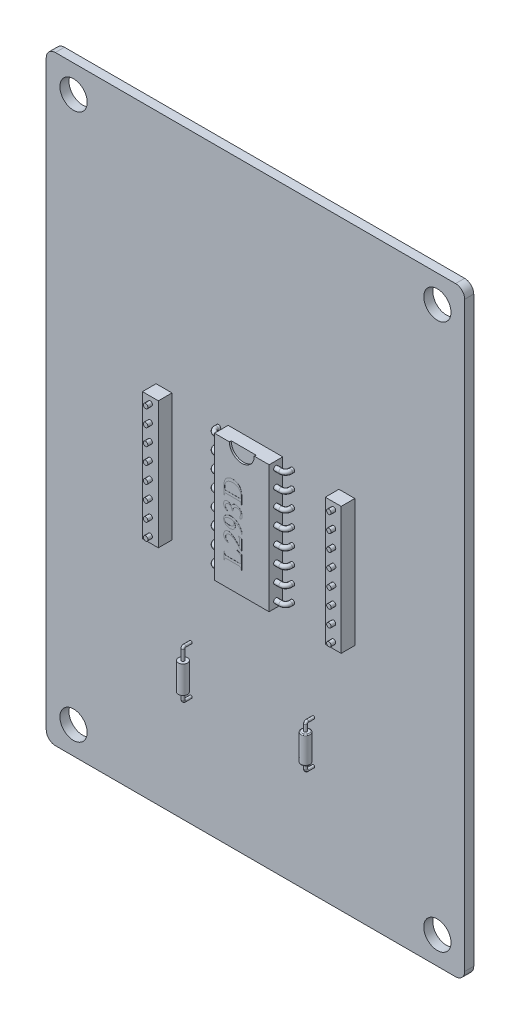
from build123d import *

# Parameters (mm, degrees)
ESQUISSE1_W                = 46
ESQUISSE1_H                = 66
ESQUISSE1_R                = 1.5
BOSS_EXTRU_1_DEPTH         = 1
CONG_1_R                   = 1
ESQUISSE2_W                = 6
ESQUISSE2_H                = 14
BOSS_EXTRU_2_DEPTH         = 1.5
ESQUISSE3_R                = 0.25
R_P_TITION_LIN_AIRE1_COUNT = 4
R_P_TITION_LIN_AIRE1_PITCH = 1.8
SYM_TRIE1_COPY_1_SKETCH_R  = 0.25
SYM_TRIE1_COPY_2_SKETCH_R  = 0.25
SYM_TRIE1_COPY_3_SKETCH_R  = 0.25
SYM_TRIE2_COPY_1_SKETCH_R  = 0.25
SYM_TRIE2_COPY_2_SKETCH_R  = 0.25
SYM_TRIE2_COPY_3_SKETCH_R  = 0.25
SYM_TRIE2_COPY_4_SKETCH_R  = 0.25
SYM_TRIE2_COPY_5_SKETCH_R  = 0.25
SYM_TRIE2_COPY_6_SKETCH_R  = 0.25
SYM_TRIE2_COPY_7_SKETCH_R  = 0.25
ENL_V_MAT_EXTRU_1_DEPTH    = 0.2
ESQUISSE7_W                = 1.747705219
ESQUISSE7_H                = 14
BOSS_EXTRU_6_DEPTH         = 1.5
BOSS_EXTRU_6_2_DEPTH       = 1.5
ESQUISSE8_R                = 0.25
BOSS_EXTRU_7_DEPTH         = 2
BOSS_EXTRU_8_START         = -20
ESQUISSE9_R                = 0.5
BOSS_EXTRU_8_DEPTH         = 3
BOSS_EXTRU_8_2_DEPTH       = 3
BOSS_EXTRU_9_START         = 0.5
ESQUISSE10_R               = 0.15
BOSS_EXTRU_9_DEPTH         = 4
ESQUISSE11_R               = 0.15
ESQUISSE12_R               = 0.15
CONG_2_R                   = 0.1
ESQUISSE13_R               = 0.15
ESQUISSE14_R               = 0.15
BOSS_EXTRU_10_DEPTH        = 0.01


with BuildPart() as part:
    # Esquisse1 → Boss.-Extru.1 (new body)
    with BuildSketch(Plane.XY):
        Rectangle(ESQUISSE1_W, ESQUISSE1_H)
        with Locations((-20, 30)):
            Circle(ESQUISSE1_R, mode=Mode.SUBTRACT)
        with Locations((20, 30)):
            Circle(ESQUISSE1_R, mode=Mode.SUBTRACT)
        with Locations((20, -30)):
            Circle(ESQUISSE1_R, mode=Mode.SUBTRACT)
        with Locations((-20, -30)):
            Circle(ESQUISSE1_R, mode=Mode.SUBTRACT)
    extrude(amount=BOSS_EXTRU_1_DEPTH)

    # Congé1
    cong_1_edges = [part.edges().sort_by_distance(p)[0] for p in [
        (23, 33, 0.5),
        (23, -33, 0.5),
        (-23, -33, 0.5),
        (-23, 33, 0.5),
    ]]
    fillet(cong_1_edges, radius=CONG_1_R)

    # Esquisse2 → Boss.-Extru.2 (add)
    with BuildSketch(Plane.XY.offset(1)):
        Rectangle(ESQUISSE2_W, ESQUISSE2_H)
    extrude(amount=BOSS_EXTRU_2_DEPTH)

    # Balayage1: sweep along a curve in space
    with BuildLine() as balayage1_path:
        Line((3, 0.9, 1.75), (3.563213592, 0.9, 1.75))
        ThreePointArc((3.563213592, 0.9, 1.75), (3.916766983, 0.9, 1.603553391), (4.063213592, 0.9, 1.25))
        Line((4.063213592, 0.9, 1.25), (4.063213592, 0.9, 0.607286013))
    # Esquisse3 → Balayage1 (sweep)
    with BuildSketch(Plane(origin=(3, 0, 0), x_dir=(0, 0, -1), z_dir=(1, 0, 0))):
        with Locations((-1.75, 0.9)):
            Circle(ESQUISSE3_R)
    balayage1 = sweep(path=balayage1_path.line)

    # Répétition linéaire1: Balayage1 ×4
    with Locations(*[(0, i * R_P_TITION_LIN_AIRE1_PITCH, 0) for i in range(1, R_P_TITION_LIN_AIRE1_COUNT)]):
        add(balayage1)

    # Symétrie1: Balayage1 across plane
    add(balayage1.mirror(Plane.ZX))

    # Symétrie1 copy 1: sweep along a curve in space
    with BuildLine() as sym_trie1_copy_1_path:
        Line((3, -2.7, 1.75), (3.563213592, -2.7, 1.75))
        ThreePointArc((3.563213592, -2.7, 1.75), (3.916766983, -2.7, 1.603553391), (4.063213592, -2.7, 1.25))
        Line((4.063213592, -2.7, 1.25), (4.063213592, -2.7, 0.607286013))
    # Symétrie1 copy 1 sketch → Symétrie1 copy 1 (sweep)
    with BuildSketch(Plane(origin=(3, -1.8, 0), x_dir=(0, 0, -1), z_dir=(1, 0, 0))):
        with Locations((-1.75, -0.9)):
            Circle(SYM_TRIE1_COPY_1_SKETCH_R)
    sweep(path=sym_trie1_copy_1_path.line)

    # Symétrie1 copy 2: sweep along a curve in space
    with BuildLine() as sym_trie1_copy_2_path:
        Line((3, -4.5, 1.75), (3.563213592, -4.5, 1.75))
        ThreePointArc((3.563213592, -4.5, 1.75), (3.916766983, -4.5, 1.603553391), (4.063213592, -4.5, 1.25))
        Line((4.063213592, -4.5, 1.25), (4.063213592, -4.5, 0.607286013))
    # Symétrie1 copy 2 sketch → Symétrie1 copy 2 (sweep)
    with BuildSketch(Plane(origin=(3, -3.6, 0), x_dir=(0, 0, -1), z_dir=(1, 0, 0))):
        with Locations((-1.75, -0.9)):
            Circle(SYM_TRIE1_COPY_2_SKETCH_R)
    sweep(path=sym_trie1_copy_2_path.line)

    # Symétrie1 copy 3: sweep along a curve in space
    with BuildLine() as sym_trie1_copy_3_path:
        Line((3, -6.3, 1.75), (3.563213592, -6.3, 1.75))
        ThreePointArc((3.563213592, -6.3, 1.75), (3.916766983, -6.3, 1.603553391), (4.063213592, -6.3, 1.25))
        Line((4.063213592, -6.3, 1.25), (4.063213592, -6.3, 0.607286013))
    # Symétrie1 copy 3 sketch → Symétrie1 copy 3 (sweep)
    with BuildSketch(Plane(origin=(3, -5.4, 0), x_dir=(0, 0, -1), z_dir=(1, 0, 0))):
        with Locations((-1.75, -0.9)):
            Circle(SYM_TRIE1_COPY_3_SKETCH_R)
    sweep(path=sym_trie1_copy_3_path.line)

    # Symétrie2: Balayage1 across plane
    add(balayage1.mirror(Plane(origin=(0, 0, 0), x_dir=(0, 0, 1), z_dir=(1, 0, 0))))

    # Symétrie2 copy 1: sweep along a curve in space
    with BuildLine() as sym_trie2_copy_1_path:
        Line((-3, 2.7, 1.75), (-3.563213592, 2.7, 1.75))
        ThreePointArc((-3.563213592, 2.7, 1.75), (-3.916766983, 2.7, 1.603553391), (-4.063213592, 2.7, 1.25))
        Line((-4.063213592, 2.7, 1.25), (-4.063213592, 2.7, 0.607286013))
    # Symétrie2 copy 1 sketch → Symétrie2 copy 1 (sweep)
    with BuildSketch(Plane(origin=(-3, 1.8, 0), x_dir=(0, 0, -1), z_dir=(-1, 0, 0))):
        with Locations((-1.75, -0.9)):
            Circle(SYM_TRIE2_COPY_1_SKETCH_R)
    sweep(path=sym_trie2_copy_1_path.line)

    # Symétrie2 copy 2: sweep along a curve in space
    with BuildLine() as sym_trie2_copy_2_path:
        Line((-3, 4.5, 1.75), (-3.563213592, 4.5, 1.75))
        ThreePointArc((-3.563213592, 4.5, 1.75), (-3.916766983, 4.5, 1.603553391), (-4.063213592, 4.5, 1.25))
        Line((-4.063213592, 4.5, 1.25), (-4.063213592, 4.5, 0.607286013))
    # Symétrie2 copy 2 sketch → Symétrie2 copy 2 (sweep)
    with BuildSketch(Plane(origin=(-3, 3.6, 0), x_dir=(0, 0, -1), z_dir=(-1, 0, 0))):
        with Locations((-1.75, -0.9)):
            Circle(SYM_TRIE2_COPY_2_SKETCH_R)
    sweep(path=sym_trie2_copy_2_path.line)

    # Symétrie2 copy 3: sweep along a curve in space
    with BuildLine() as sym_trie2_copy_3_path:
        Line((-3, 6.3, 1.75), (-3.563213592, 6.3, 1.75))
        ThreePointArc((-3.563213592, 6.3, 1.75), (-3.916766983, 6.3, 1.603553391), (-4.063213592, 6.3, 1.25))
        Line((-4.063213592, 6.3, 1.25), (-4.063213592, 6.3, 0.607286013))
    # Symétrie2 copy 3 sketch → Symétrie2 copy 3 (sweep)
    with BuildSketch(Plane(origin=(-3, 5.4, 0), x_dir=(0, 0, -1), z_dir=(-1, 0, 0))):
        with Locations((-1.75, -0.9)):
            Circle(SYM_TRIE2_COPY_3_SKETCH_R)
    sweep(path=sym_trie2_copy_3_path.line)

    # Symétrie2 copy 4: sweep along a curve in space
    with BuildLine() as sym_trie2_copy_4_path:
        Line((-3, -0.9, 1.75), (-3.563213592, -0.9, 1.75))
        ThreePointArc((-3.563213592, -0.9, 1.75), (-3.916766983, -0.9, 1.603553391), (-4.063213592, -0.9, 1.25))
        Line((-4.063213592, -0.9, 1.25), (-4.063213592, -0.9, 0.607286013))
    # Symétrie2 copy 4 sketch → Symétrie2 copy 4 (sweep)
    with BuildSketch(Plane(origin=(-3, 0, 0), x_dir=(0, 0, -1), z_dir=(-1, 0, 0))):
        with Locations((-1.75, 0.9)):
            Circle(SYM_TRIE2_COPY_4_SKETCH_R)
    sweep(path=sym_trie2_copy_4_path.line)

    # Symétrie2 copy 5: sweep along a curve in space
    with BuildLine() as sym_trie2_copy_5_path:
        Line((-3, -2.7, 1.75), (-3.563213592, -2.7, 1.75))
        ThreePointArc((-3.563213592, -2.7, 1.75), (-3.916766983, -2.7, 1.603553391), (-4.063213592, -2.7, 1.25))
        Line((-4.063213592, -2.7, 1.25), (-4.063213592, -2.7, 0.607286013))
    # Symétrie2 copy 5 sketch → Symétrie2 copy 5 (sweep)
    with BuildSketch(Plane(origin=(-3, -1.8, 0), x_dir=(0, 0, -1), z_dir=(-1, 0, 0))):
        with Locations((-1.75, 0.9)):
            Circle(SYM_TRIE2_COPY_5_SKETCH_R)
    sweep(path=sym_trie2_copy_5_path.line)

    # Symétrie2 copy 6: sweep along a curve in space
    with BuildLine() as sym_trie2_copy_6_path:
        Line((-3, -4.5, 1.75), (-3.563213592, -4.5, 1.75))
        ThreePointArc((-3.563213592, -4.5, 1.75), (-3.916766983, -4.5, 1.603553391), (-4.063213592, -4.5, 1.25))
        Line((-4.063213592, -4.5, 1.25), (-4.063213592, -4.5, 0.607286013))
    # Symétrie2 copy 6 sketch → Symétrie2 copy 6 (sweep)
    with BuildSketch(Plane(origin=(-3, -3.6, 0), x_dir=(0, 0, -1), z_dir=(-1, 0, 0))):
        with Locations((-1.75, 0.9)):
            Circle(SYM_TRIE2_COPY_6_SKETCH_R)
    sweep(path=sym_trie2_copy_6_path.line)

    # Symétrie2 copy 7: sweep along a curve in space
    with BuildLine() as sym_trie2_copy_7_path:
        Line((-3, -6.3, 1.75), (-3.563213592, -6.3, 1.75))
        ThreePointArc((-3.563213592, -6.3, 1.75), (-3.916766983, -6.3, 1.603553391), (-4.063213592, -6.3, 1.25))
        Line((-4.063213592, -6.3, 1.25), (-4.063213592, -6.3, 0.607286013))
    # Symétrie2 copy 7 sketch → Symétrie2 copy 7 (sweep)
    with BuildSketch(Plane(origin=(-3, -5.4, 0), x_dir=(0, 0, -1), z_dir=(-1, 0, 0))):
        with Locations((-1.75, 0.9)):
            Circle(SYM_TRIE2_COPY_7_SKETCH_R)
    sweep(path=sym_trie2_copy_7_path.line)

    # Esquisse4 → Enlèv. mat.-Extru.1 (cut)
    with BuildSketch(Plane.XY.offset(2.5)):
        with BuildLine():
            Line((-1.366788439, 7), (1.366788439, 7))
            ThreePointArc((1.366788439, 7), (0, 5.633211561), (-1.366788439, 7))
        make_face()
    extrude(amount=-ENL_V_MAT_EXTRU_1_DEPTH, mode=Mode.SUBTRACT)



with BuildPart() as body_2:
    # Esquisse7 → Boss.-Extru.6 (new body)
    with BuildSketch(Plane.XY.offset(2.5)):
        with Locations((-10.04930501, 0)):
            Rectangle(ESQUISSE7_W, ESQUISSE7_H)
    extrude(amount=-BOSS_EXTRU_6_DEPTH)

    # Esquisse8 → Boss.-Extru.7 (add)
    with BuildSketch(Plane(origin=(0, 0, 1), x_dir=(-1, 0, 0), z_dir=(0, 0, -1))):
        with Locations((-10.084279429, 0.9)):
            Circle(ESQUISSE8_R)
        with Locations((-10.080629218, 2.699996299)):
            Circle(ESQUISSE8_R)
        with Locations((-10.076979007, 4.499992598)):
            Circle(ESQUISSE8_R)
        with Locations((-10.073328797, 6.299988897)):
            Circle(ESQUISSE8_R)
        with Locations(Location((-10.073328797, -6.299988897, 0), (0, 0, 180))):
            Circle(ESQUISSE8_R)
        with Locations(Location((-10.076979007, -4.499992598, 0), (0, 0, 180))):
            Circle(ESQUISSE8_R)
        with Locations(Location((-10.080629218, -2.699996299, 0), (0, 0, 180))):
            Circle(ESQUISSE8_R)
        with Locations(Location((-10.084279429, -0.9, 0), (0, 0, 180))):
            Circle(ESQUISSE8_R)
        with Locations((10.084279429, -0.9)):
            Circle(ESQUISSE8_R)
        with Locations((10.080629218, -2.699996299)):
            Circle(ESQUISSE8_R)
        with Locations((10.076979007, -4.499992598)):
            Circle(ESQUISSE8_R)
        with Locations((10.073328797, -6.299988897)):
            Circle(ESQUISSE8_R)
        with Locations((10.073328797, 6.299988897)):
            Circle(ESQUISSE8_R)
        with Locations((10.076979007, 4.499992598)):
            Circle(ESQUISSE8_R)
        with Locations((10.080629218, 2.699996299)):
            Circle(ESQUISSE8_R)
        with Locations((10.084279429, 0.9)):
            Circle(ESQUISSE8_R)
    extrude(amount=-BOSS_EXTRU_7_DEPTH)


with BuildPart() as body_3:
    # Esquisse7 → Boss.-Extru.6 2 (new body)
    with BuildSketch(Plane.XY.offset(2.5)):
        with Locations((10.04930501, 0)):
            Rectangle(ESQUISSE7_W, ESQUISSE7_H)
    extrude(amount=-BOSS_EXTRU_6_2_DEPTH)


with BuildPart() as boss_extru_7_piece_1:
    # of the separate pieces the step leaves, piece 1, a body of its own (boss_extru_7_pieces)
    add(body_2.part.solids().sort_by_distance((-9.1754524, 7, 2.5))[0])


with BuildPart() as boss_extru_7_piece_2:
    # of the separate pieces the step leaves, piece 2, a body of its own (boss_extru_7_pieces)
    add(body_2.part.solids().sort_by_distance((10.326979007, -4.499992598, 1))[0])


with BuildPart() as boss_extru_7_piece_3:
    # of the separate pieces the step leaves, piece 3, a body of its own (boss_extru_7_pieces)
    add(body_2.part.solids().sort_by_distance((10.330629218, -2.699996299, 1))[0])


with BuildPart() as boss_extru_7_piece_4:
    # of the separate pieces the step leaves, piece 4, a body of its own (boss_extru_7_pieces)
    add(body_2.part.solids().sort_by_distance((10.334279429, -0.9, 1))[0])


with BuildPart() as boss_extru_7_piece_5:
    # of the separate pieces the step leaves, piece 5, a body of its own (boss_extru_7_pieces)
    add(body_2.part.solids().sort_by_distance((9.834279429, 0.9, 1))[0])


with BuildPart() as boss_extru_7_piece_6:
    # of the separate pieces the step leaves, piece 6, a body of its own (boss_extru_7_pieces)
    add(body_2.part.solids().sort_by_distance((9.830629218, 2.699996299, 1))[0])


with BuildPart() as boss_extru_7_piece_7:
    # of the separate pieces the step leaves, piece 7, a body of its own (boss_extru_7_pieces)
    add(body_2.part.solids().sort_by_distance((9.826979007, 4.499992598, 1))[0])


with BuildPart() as boss_extru_7_piece_8:
    # of the separate pieces the step leaves, piece 8, a body of its own (boss_extru_7_pieces)
    add(body_2.part.solids().sort_by_distance((9.823328797, 6.299988897, 1))[0])


with BuildPart() as boss_extru_7_piece_9:
    # of the separate pieces the step leaves, piece 9, a body of its own (boss_extru_7_pieces)
    add(body_2.part.solids().sort_by_distance((10.323328797, -6.299988897, 1))[0])


with BuildPart() as body_12:
    # Esquisse9 → Boss.-Extru.8 (new body)
    with BuildSketch(Plane(origin=(0, 0, 0), x_dir=(1, 0, 0), z_dir=(0, 1, 0)).offset(BOSS_EXTRU_8_START)):
        with Locations(Location((6.366458471, -1.857679009, 0), (0, 0, 270))):
            Circle(ESQUISSE9_R)
    extrude(amount=BOSS_EXTRU_8_DEPTH)

    # Esquisse10 → Boss.-Extru.9 (add)
    with BuildSketch(Plane.XZ.offset(20).offset(BOSS_EXTRU_9_START)):
        with Locations(Location((6.366458471, 1.857679009, 0), (0, 0, 270))):
            Circle(ESQUISSE10_R)
    extrude(amount=-BOSS_EXTRU_9_DEPTH)


with BuildPart() as body_13:
    # Esquisse9 → Boss.-Extru.8 2 (new body)
    with BuildSketch(Plane(origin=(0, 0, 0), x_dir=(1, 0, 0), z_dir=(0, 1, 0)).offset(BOSS_EXTRU_8_START)):
        with Locations(Location((-7.110417285, -1.857679009, 0), (0, 0, 270))):
            Circle(ESQUISSE9_R)
    extrude(amount=BOSS_EXTRU_8_2_DEPTH)


with BuildPart() as part_1:
    add(part.part)

    add(body_12.part)  # Balayage2 merges body 12
    # Balayage2: sweep along a curve in space
    with BuildLine() as balayage2_path:
        Line((6.366458471, -20.5, 1.857679009), (6.366458471, -20.593357663, 1.857679009))
        ThreePointArc((6.366458471, -20.593357663, 1.857679009), (6.366458471, -20.713565816, 1.807887162), (6.366458471, -20.763357663, 1.687679009))
        Line((6.366458471, -20.763357663, 1.687679009), (6.366458471, -20.763357663, 0.482310177))
    # Esquisse11 → Balayage2 (sweep)
    with BuildSketch(Plane.XZ.offset(20.5)):
        with Locations((6.366458471, 1.857679009)):
            Circle(ESQUISSE11_R)
    sweep(path=balayage2_path.line)

    # Balayage3: sweep along a curve in space
    with BuildLine() as balayage3_path:
        Line((6.366458471, -16.5, 1.857679009), (6.366458471, -16.288204336, 1.857679009))
        ThreePointArc((6.366458471, -16.288204336, 1.857679009), (6.366458471, -16.167996183, 1.807887162), (6.366458471, -16.118204336, 1.687679009))
        Line((6.366458471, -16.118204336, 1.687679009), (6.366458471, -16.118204336, 0.83860797))
    # Esquisse12 → Balayage3 (sweep)
    with BuildSketch(Plane(origin=(0, -16.5, 0), x_dir=(1, 0, 0), z_dir=(0, 1, 0))):
        with Locations((6.366458471, -1.857679009)):
            Circle(ESQUISSE12_R)
    sweep(path=balayage3_path.line)

    # Congé2
    cong_2_edges = [part_1.edges().sort_by_distance(p)[0] for p in [
        (6.366458471, -20, 1.357679009),
        (6.366458471, -17, 1.357679009),
    ]]
    fillet(cong_2_edges, radius=CONG_2_R)


    add(body_13.part)  # Balayage4 merges body 13
    # Balayage4: sweep along a curve in space
    with BuildLine() as balayage4_path:
        Line((-7.110417285, -20, 1.857679009), (-7.110417285, -20.721237624, 1.857679009))
        ThreePointArc((-7.110417285, -20.721237624, 1.857679009), (-7.110417285, -20.841445777, 1.807887162), (-7.110417285, -20.891237624, 1.687679009))
        Line((-7.110417285, -20.891237624, 1.687679009), (-7.110417285, -20.891237624, 0.537103228))
    # Esquisse13 → Balayage4 (sweep)
    with BuildSketch(Plane.XZ.offset(20)):
        with Locations((-7.110417285, 1.857679009)):
            Circle(ESQUISSE13_R)
    sweep(path=balayage4_path.line)

    # Balayage5: sweep along a curve in space
    with BuildLine() as balayage5_path:
        Line((-7.110417285, -17, 1.857679009), (-7.110417285, -15.861264901, 1.857679009))
        ThreePointArc((-7.110417285, -15.861264901, 1.857679009), (-7.110417285, -15.741056749, 1.807887162), (-7.110417285, -15.691264901, 1.687679009))
        Line((-7.110417285, -15.691264901, 1.687679009), (-7.110417285, -15.691264901, 0.564119336))
    # Esquisse14 → Balayage5 (sweep)
    with BuildSketch(Plane(origin=(0, -17, 0), x_dir=(1, 0, 0), z_dir=(0, 1, 0))):
        with Locations((-7.110417285, -1.857679009)):
            Circle(ESQUISSE14_R)
    sweep(path=balayage5_path.line)

    # Esquisse15 → Boss.-Extru.10 (add)
    with BuildSketch(Plane.XY.offset(2.5)):
        with BuildLine():
            Line((0, 1.651210137), (-0.054355951, 1.651210137))
            Line((-0.054355951, 1.651210137), (-0.054355951, 1.722127667))
            add(Edge.make_bspline(
                [(-0.054355951, 1.722127667), (-0.05458343, 1.731766297), (-0.055023593, 1.75041673), (-0.058886138, 1.777336556), (-0.065227282, 1.802134582), (-0.07398273, 1.824827311), (-0.085873494, 1.844963627), (-0.099237959, 1.863611596), (-0.116144767, 1.879461129), (-0.128967843, 1.888058455), (-0.135465222, 1.89241467)],
                knots=[0, 0, 0, 0, 1.170016541, 2.263943595, 3.293731011, 4.273677885, 5.205400736, 6.126759273, 7.050839703, 8, 8, 8, 8], degree=3))
            add(Edge.make_bspline(
                [(-0.135465222, 1.89241467), (-0.140078053, 1.894946828), (-0.150232806, 1.900521157), (-0.168291065, 1.906668376), (-0.189965971, 1.91150574), (-0.215339679, 1.915799076), (-0.244409124, 1.918996482), (-0.277396867, 1.921671063), (-0.314096938, 1.922727976), (-0.339866172, 1.922900081), (-0.353313682, 1.922989892)],
                knots=[0, 0, 0, 0, 0.568141805, 1.250715472, 2.052584266, 2.968455247, 4.031571596, 5.213625719, 6.545948453, 8, 8, 8, 8], degree=3))
            Line((-0.353313682, 1.922989892), (-1.603500555, 1.922989892))
            add(Edge.make_bspline(
                [(-1.603500555, 1.922989892), (-1.618368175, 1.923009834), (-1.646564068, 1.923047653), (-1.686763953, 1.920612922), (-1.722640622, 1.917947787), (-1.754128356, 1.913784746), (-1.781289465, 1.908358246), (-1.803952994, 1.901597102), (-1.823015662, 1.89445859), (-1.832928866, 1.887239943), (-1.837485937, 1.883921553)],
                knots=[0, 0, 0, 0, 1.484107705, 2.814555366, 4.019988359, 5.075390106, 5.984573864, 6.780592097, 7.4394417, 8, 8, 8, 8], degree=3))
            add(Edge.make_bspline(
                [(-1.837485937, 1.883921553), (-1.847533636, 1.874183108), (-1.867732376, 1.854606057), (-1.888311632, 1.81599763), (-1.900177999, 1.771105075), (-1.901670297, 1.739052568), (-1.902458285, 1.722127667)],
                knots=[0, 0, 0, 0, 0.928124107, 1.865794122, 2.873060895, 4, 4, 4, 4], degree=3))
            Line((-1.902458285, 1.722127667), (-1.902458285, 1.651210137))
            Line((-1.902458285, 1.651210137), (-1.956814236, 1.651210137))
            Line((-1.956814236, 1.651210137), (-1.956814236, 2.452960415))
            add(Edge.make_bspline(
                [(-1.956814236, 2.452960415), (-1.956480802, 2.488637507), (-1.955833484, 2.557899947), (-1.951068184, 2.658451702), (-1.943775296, 2.752562469), (-1.932530814, 2.839770726), (-1.919458219, 2.920736686), (-1.90180255, 2.994753338), (-1.882291554, 3.062649022), (-1.858678173, 3.124303529), (-1.83094772, 3.181008885), (-1.800075827, 3.234746236), (-1.764669734, 3.285448089), (-1.724913983, 3.333196648), (-1.681154757, 3.378162988), (-1.63341708, 3.420457258), (-1.581271098, 3.459509967), (-1.525620972, 3.495859675), (-1.466609703, 3.528566298), (-1.404965164, 3.556969596), (-1.340996155, 3.581308304), (-1.274877483, 3.60119419), (-1.206497318, 3.6166911), (-1.135901148, 3.626861225), (-1.063066615, 3.634191869), (-1.01367273, 3.634862113), (-0.988598859, 3.635202349)],
                knots=[0, 0, 0, 0, 1.467285284, 2.848543714, 4.139428074, 5.348239071, 6.464224292, 7.510631955, 8.47589724, 9.36787262, 10.221917022, 11.069687826, 11.914354515, 12.761885405, 13.622354629, 14.49261558, 15.382193837, 16.299385727, 17.224488554, 18.154414988, 19.088614209, 20.037143359, 20.991923033, 21.969244678, 22.969125506, 24, 24, 24, 24], degree=3))
            add(Edge.make_bspline(
                [(-0.988598859, 3.635202349), (-0.955153773, 3.634544078), (-0.88959987, 3.633253838), (-0.793432427, 3.620866513), (-0.701463286, 3.601517632), (-0.613483046, 3.574365875), (-0.529888178, 3.538941062), (-0.450574071, 3.495622826), (-0.374727868, 3.445459576), (-0.328836301, 3.405569796), (-0.305752224, 3.385504699)],
                knots=[0, 0, 0, 0, 1.077719575, 2.112379846, 3.120154608, 4.104514829, 5.075810074, 6.041644454, 7.014920789, 8, 8, 8, 8], degree=3))
            add(Edge.make_bspline(
                [(-0.305752224, 3.385504699), (-0.293272974, 3.373634782), (-0.268225796, 3.349810601), (-0.233596401, 3.311097546), (-0.201214032, 3.270290468), (-0.171373193, 3.227113411), (-0.143822944, 3.181763374), (-0.118598321, 3.134024707), (-0.096310134, 3.083801334), (-0.07576768, 3.031604517), (-0.058023439, 2.976946815), (-0.042279668, 2.920165109), (-0.029073639, 2.860923053), (-0.018677404, 2.799369823), (-0.010056382, 2.735656696), (-0.004170012, 2.669628129), (-0.000822322, 2.601342093), (-0.000276791, 2.555023022), (0, 2.53152175)],
                knots=[0, 0, 0, 0, 0.884547214, 1.775380039, 2.665826882, 3.559504879, 4.469980105, 5.390593375, 6.331323642, 7.291529335, 8.271228182, 9.282197471, 10.317896576, 11.387954191, 12.488469157, 13.620281033, 14.792583212, 16, 16, 16, 16], degree=3))
            Line((0, 2.53152175), (0, 1.651210137))
        make_face()
        with BuildLine():
            add(Edge.make_bspline(
                [(-0.123150201, 2.194769647), (-0.116805136, 2.224871339), (-0.104694574, 2.28232518), (-0.091423351, 2.365188196), (-0.083261897, 2.440480341), (-0.082088091, 2.488189616), (-0.081533927, 2.510713613)],
                knots=[0, 0, 0, 0, 1.156186088, 2.206764045, 3.153396487, 4, 4, 4, 4], degree=3))
            add(Edge.make_bspline(
                [(-0.081533927, 2.510713613), (-0.082233912, 2.538783083), (-0.083611649, 2.594030449), (-0.095503122, 2.674932992), (-0.114033588, 2.752400962), (-0.1404464, 2.82619692), (-0.174626914, 2.896253649), (-0.216483812, 2.9624922), (-0.266288203, 3.024595025), (-0.32240598, 3.083267159), (-0.385617263, 3.136032446), (-0.454286406, 3.18276113), (-0.52857313, 3.221859778), (-0.608177421, 3.253759568), (-0.693029329, 3.278904177), (-0.783458008, 3.296510055), (-0.879197655, 3.307325075), (-0.944829897, 3.308477213), (-0.978407118, 3.309066643)],
                knots=[0, 0, 0, 0, 0.997996022, 1.964292496, 2.902202989, 3.827540679, 4.746320531, 5.669683403, 6.608607029, 7.573643287, 8.552931756, 9.531909504, 10.522958759, 11.532773866, 12.577887131, 13.666093008, 14.805981493, 16, 16, 16, 16], degree=3))
            add(Edge.make_bspline(
                [(-0.978407118, 3.309066643), (-1.012266976, 3.308478626), (-1.078322212, 3.307331497), (-1.174495242, 3.296557866), (-1.26518493, 3.278844275), (-1.350321062, 3.253749101), (-1.430268881, 3.221965113), (-1.504630965, 3.182732124), (-1.573289848, 3.136165495), (-1.636077483, 3.083216392), (-1.692084733, 3.024524027), (-1.741195898, 2.961587507), (-1.782678914, 2.894334554), (-1.816905064, 2.823094341), (-1.843227438, 2.747568563), (-1.861866007, 2.668155625), (-1.873095567, 2.584783714), (-1.8745419, 2.527876568), (-1.87528031, 2.498823248)],
                knots=[0, 0, 0, 0, 1.19331062, 2.327960612, 3.406430637, 4.446978843, 5.452389227, 6.434571861, 7.404790988, 8.371500382, 9.324446655, 10.2597346, 11.18065483, 12.104692875, 13.040566373, 13.994348472, 14.976036595, 16, 16, 16, 16], degree=3))
            add(Edge.make_bspline(
                [(-1.87528031, 2.498823248), (-1.87477575, 2.475870997), (-1.873726408, 2.428136782), (-1.865144351, 2.354380263), (-1.851458396, 2.275880922), (-1.838898634, 2.22245525), (-1.832390067, 2.194769647)],
                knots=[0, 0, 0, 0, 0.894670856, 1.860663297, 2.891378894, 4, 4, 4, 4], degree=3))
            Line((-1.832390067, 2.194769647), (-0.123150201, 2.194769647))
        make_face(mode=Mode.SUBTRACT)
        with BuildLine():
            add(Edge.make_bspline(
                [(-1.576322579, 0.292311362), (-1.592231545, 0.299410785), (-1.623345329, 0.313295402), (-1.668184039, 0.335741179), (-1.709997766, 0.360034497), (-1.748885435, 0.38604033), (-1.785561257, 0.412633364), (-1.819360125, 0.440685667), (-1.849894261, 0.470611696), (-1.87809907, 0.501586875), (-1.903504839, 0.534204024), (-1.924525536, 0.569404104), (-1.943156464, 0.605997252), (-1.95772641, 0.644839375), (-1.970043356, 0.685299086), (-1.977649169, 0.727933358), (-1.983119963, 0.772314174), (-1.983697514, 0.802588014), (-1.983992212, 0.818035326)],
                knots=[0, 0, 0, 0, 1.176172112, 2.300285512, 3.383809406, 4.438801016, 5.45767614, 6.441523458, 7.401261385, 8.341820402, 9.268929944, 10.186831035, 11.105776411, 12.037603097, 12.984164096, 13.956994367, 14.957550633, 16, 16, 16, 16], degree=3))
            add(Edge.make_bspline(
                [(-1.983992212, 0.818035326), (-1.983439706, 0.836878177), (-1.982360107, 0.873697218), (-1.975809319, 0.927267629), (-1.963714853, 0.977459311), (-1.947308191, 1.02425137), (-1.926002581, 1.067776448), (-1.899152512, 1.107232875), (-1.868888902, 1.14449824), (-1.844620426, 1.165457552), (-1.832390067, 1.176020222)],
                knots=[0, 0, 0, 0, 1.123808988, 2.195929207, 3.211426243, 4.196579678, 5.14788152, 6.09136163, 7.038121192, 8, 8, 8, 8], degree=3))
            add(Edge.make_bspline(
                [(-1.832390067, 1.176020222), (-1.813757275, 1.190636734), (-1.777691301, 1.218928723), (-1.717023827, 1.248109403), (-1.654927308, 1.267373776), (-1.612416538, 1.269604432), (-1.591185534, 1.27071848)],
                knots=[0, 0, 0, 0, 1.0718399, 2.074673036, 3.038440762, 4, 4, 4, 4], degree=3))
            add(Edge.make_bspline(
                [(-1.591185534, 1.27071848), (-1.573417879, 1.269878339), (-1.537298409, 1.268170433), (-1.483242327, 1.254595379), (-1.428920202, 1.233094291), (-1.374304095, 1.202908339), (-1.319373703, 1.164149944), (-1.263782802, 1.117327243), (-1.207994287, 1.061782853), (-1.172609282, 1.020433752), (-1.154214647, 0.998938725)],
                knots=[0, 0, 0, 0, 0.802544778, 1.631475345, 2.504987027, 3.438672434, 4.445331875, 5.540090885, 6.721234327, 8, 8, 8, 8], degree=3))
            add(Edge.make_bspline(
                [(-1.154214647, 0.998938725), (-1.148335679, 1.013187262), (-1.136804389, 1.041135023), (-1.116228983, 1.080826217), (-1.093591003, 1.117604862), (-1.070032957, 1.152341895), (-1.043882057, 1.183903649), (-1.015825675, 1.212779974), (-0.986014397, 1.23918022), (-0.954627293, 1.263092315), (-0.921269396, 1.283938592), (-0.886425012, 1.302092488), (-0.850416558, 1.318078769), (-0.812611674, 1.330260156), (-0.773586547, 1.340002689), (-0.733176802, 1.347279377), (-0.691295453, 1.351644023), (-0.662898346, 1.352047243), (-0.648449509, 1.352252407)],
                knots=[0, 0, 0, 0, 1.121628463, 2.200015641, 3.249715177, 4.264389965, 5.252559056, 6.229000805, 7.192526379, 8.148751574, 9.09789992, 10.051957494, 11.00718286, 11.961907919, 12.939056191, 13.933490933, 14.948531889, 16, 16, 16, 16], degree=3))
            add(Edge.make_bspline(
                [(-0.648449509, 1.352252407), (-0.627761773, 1.351746729), (-0.587107618, 1.350753004), (-0.527129769, 1.343369074), (-0.469253503, 1.331145154), (-0.413569804, 1.313659901), (-0.35995499, 1.291404137), (-0.308484955, 1.264137573), (-0.259000535, 1.231855686), (-0.228254764, 1.206875541), (-0.212752589, 1.194280424)],
                knots=[0, 0, 0, 0, 1.047990644, 2.059441063, 3.056756804, 4.041224851, 5.012198649, 5.993919813, 6.988524153, 8, 8, 8, 8], degree=3))
            add(Edge.make_bspline(
                [(-0.212752589, 1.194280424), (-0.193595027, 1.176618417), (-0.155398987, 1.141404192), (-0.10660062, 1.080464015), (-0.065162666, 1.014119029), (-0.030789637, 0.942137565), (-0.004670506, 0.864081147), (0.013907167, 0.780397985), (0.025036171, 0.691079824), (0.02645038, 0.629662256), (0.027177976, 0.598063587)],
                knots=[0, 0, 0, 0, 0.9408645, 1.875880513, 2.811526398, 3.763677692, 4.752375993, 5.780273647, 6.857974994, 8, 8, 8, 8], degree=3))
            add(Edge.make_bspline(
                [(0.027177976, 0.598063587), (0.026999382, 0.582631616), (0.026656764, 0.553026574), (0.024506582, 0.510534981), (0.021294174, 0.471825404), (0.016368786, 0.436893842), (0.009387512, 0.405931905), (0.002064432, 0.378504996), (-0.007128958, 0.354854096), (-0.021513859, 0.329978811), (-0.040304203, 0.304745834), (-0.065174472, 0.28265462), (-0.090952922, 0.267676094), (-0.109250037, 0.265959423), (-0.118054331, 0.265133387)],
                knots=[0, 0, 0, 0, 1.402226433, 2.690062984, 3.865046374, 4.930988681, 5.892224942, 6.747350114, 7.509271635, 8.188907461, 9.354277059, 10.347676201, 11.204926872, 12, 12, 12, 12], degree=3))
            add(Edge.make_bspline(
                [(-0.118054331, 0.265133387), (-0.124472596, 0.26555828), (-0.137166657, 0.266398636), (-0.155608948, 0.272725384), (-0.172839509, 0.283125919), (-0.188204484, 0.297571578), (-0.201522081, 0.314579138), (-0.210119262, 0.334262185), (-0.21679698, 0.354868943), (-0.217211946, 0.369399456), (-0.217423804, 0.37681788)],
                knots=[0, 0, 0, 0, 0.929571062, 1.83850789, 2.796220289, 3.827879728, 4.883170332, 5.902705477, 6.929244986, 8, 8, 8, 8], degree=3))
            add(Edge.make_bspline(
                [(-0.217423804, 0.37681788), (-0.216900508, 0.38860902), (-0.215833313, 0.41265551), (-0.210698397, 0.436173875), (-0.208081375, 0.448160066)],
                knots=[0, 0, 0, 0, 0.980695293, 2, 2, 2, 2], degree=3))
            add(Edge.make_bspline(
                [(-0.208081375, 0.448160066), (-0.206419001, 0.453409616), (-0.202295598, 0.466430758), (-0.193628692, 0.489573883), (-0.18060692, 0.519921708), (-0.165641824, 0.555810609), (-0.149894357, 0.591995488), (-0.136598571, 0.62397367), (-0.127328665, 0.64977106), (-0.123216551, 0.664994818), (-0.121451578, 0.671529052)],
                knots=[0, 0, 0, 0, 0.551118922, 1.367011757, 2.472159805, 3.856335036, 5.2590945, 6.422039383, 7.322718894, 8, 8, 8, 8], degree=3))
            add(Edge.make_bspline(
                [(-0.121451578, 0.671529052), (-0.117632303, 0.68915676), (-0.109780872, 0.725394726), (-0.109074609, 0.762473078), (-0.108711902, 0.781514921)],
                knots=[0, 0, 0, 0, 0.972886197, 2, 2, 2, 2], degree=3))
            add(Edge.make_bspline(
                [(-0.108711902, 0.781514921), (-0.108977489, 0.793291004), (-0.109502121, 0.816553083), (-0.115505739, 0.850615425), (-0.123700657, 0.883641235), (-0.13626382, 0.915392093), (-0.152545596, 0.94578085), (-0.171646983, 0.975488773), (-0.194832091, 1.003437638), (-0.220956573, 1.030033608), (-0.2496283, 1.054311306), (-0.279579771, 1.076278335), (-0.311345768, 1.093878721), (-0.343901953, 1.109330742), (-0.37826615, 1.120334604), (-0.413651127, 1.129242911), (-0.450444678, 1.133727525), (-0.475321916, 1.134458266), (-0.487929591, 1.134828603)],
                knots=[0, 0, 0, 0, 0.982851217, 1.941491267, 2.882456302, 3.822528864, 4.785464342, 5.759809577, 6.768441881, 7.813919766, 8.871041413, 9.905015024, 10.911425668, 11.901085576, 12.910965416, 13.920775988, 14.946258393, 16, 16, 16, 16], degree=3))
            add(Edge.make_bspline(
                [(-0.487929591, 1.134828603), (-0.506655034, 1.134276631), (-0.544035054, 1.133174777), (-0.599447703, 1.123639698), (-0.654478886, 1.109623046), (-0.689649828, 1.095068806), (-0.707476675, 1.087691802)],
                knots=[0, 0, 0, 0, 0.993065039, 1.982371906, 2.977339071, 4, 4, 4, 4], degree=3))
            add(Edge.make_bspline(
                [(-0.707476675, 1.087691802), (-0.720060471, 1.081987529), (-0.744153857, 1.071065925), (-0.776627321, 1.051647008), (-0.805364461, 1.032643787), (-0.82104725, 1.017570835), (-0.828503597, 1.010404434)],
                knots=[0, 0, 0, 0, 1.146959708, 2.196010144, 3.142297047, 4, 4, 4, 4], degree=3))
            add(Edge.make_bspline(
                [(-0.828503597, 1.010404434), (-0.83812592, 1.000156831), (-0.858194562, 0.978784085), (-0.883867929, 0.94072137), (-0.909672552, 0.898353459), (-0.932856515, 0.851003233), (-0.953238929, 0.801138228), (-0.967910293, 0.749481779), (-0.97653692, 0.697301071), (-0.977786099, 0.662217338), (-0.978407118, 0.644775732)],
                knots=[0, 0, 0, 0, 0.83384287, 1.739090775, 2.719783015, 3.780330508, 4.867190307, 5.916037577, 6.963974228, 8, 8, 8, 8], degree=3))
            Line((-0.978407118, 0.644775732), (-0.978407118, 0.601460834))
            Line((-0.978407118, 0.601460834), (-1.032763069, 0.601460834))
            add(Edge.make_bspline(
                [(-1.032763069, 0.601460834), (-1.035744682, 0.620797491), (-1.041780882, 0.659944072), (-1.058776281, 0.718026721), (-1.082385884, 0.775920915), (-1.111635612, 0.832637774), (-1.145176632, 0.885966167), (-1.182857848, 0.932576206), (-1.224181452, 0.971267164), (-1.269122768, 1.001495059), (-1.31684748, 1.024604015), (-1.366768876, 1.041292459), (-1.419086082, 1.051291941), (-1.454686607, 1.052621628), (-1.472706547, 1.053294676)],
                knots=[0, 0, 0, 0, 1.018935223, 2.062808912, 3.145188716, 4.273734709, 5.385122712, 6.423375209, 7.389238933, 8.324434281, 9.235182206, 10.145122849, 11.061115619, 12, 12, 12, 12], degree=3))
            add(Edge.make_bspline(
                [(-1.472706547, 1.053294676), (-1.484333913, 1.053136581), (-1.507263761, 1.052824807), (-1.540608096, 1.047797514), (-1.572606944, 1.040839687), (-1.602499671, 1.030034466), (-1.631093357, 1.017001514), (-1.657292749, 0.99996537), (-1.682764753, 0.981176238), (-1.705172753, 0.958423071), (-1.726210069, 0.93449312), (-1.74409702, 0.908292705), (-1.759200262, 0.880745849), (-1.772396815, 0.851963572), (-1.781923952, 0.821533375), (-1.78870573, 0.789677739), (-1.793173433, 0.756445581), (-1.793552712, 0.733685227), (-1.793746383, 0.7220631)],
                knots=[0, 0, 0, 0, 1.07791789, 2.125717433, 3.123144222, 4.111969722, 5.069857656, 6.032059613, 7.006823601, 8.000784083, 8.988212443, 9.96111577, 10.93720663, 11.90155836, 12.894476591, 13.889044549, 14.92208211, 16, 16, 16, 16], degree=3))
            add(Edge.make_bspline(
                [(-1.793746383, 0.7220631), (-1.792983285, 0.703469158), (-1.791472513, 0.666657124), (-1.780221234, 0.612455454), (-1.760820308, 0.560822373), (-1.734213732, 0.51155912), (-1.700159679, 0.464790887), (-1.658469354, 0.420560715), (-1.60950869, 0.378195986), (-1.572511186, 0.353489996), (-1.553391162, 0.340722131)],
                knots=[0, 0, 0, 0, 0.945880324, 1.872641027, 2.802587732, 3.743710782, 4.713428731, 5.737868988, 6.830948165, 8, 8, 8, 8], degree=3))
            Line((-1.553391162, 0.340722131), (-1.576322579, 0.292311362))
        make_face()
        with BuildLine():
            Line((0.027177976, -1.148121339), (-0.027177976, -1.148121339))
            add(Edge.make_bspline(
                [(-0.027177976, -1.148121339), (-0.028602379, -1.118185306), (-0.031424092, -1.058882639), (-0.047894184, -0.971690721), (-0.074602242, -0.887888425), (-0.104463921, -0.820532251), (-0.134450427, -0.768664339), (-0.16049461, -0.729637031), (-0.190752175, -0.691310394), (-0.224344681, -0.65275606), (-0.262310795, -0.615132826), (-0.30396913, -0.577704197), (-0.349655211, -0.540832266), (-0.398327022, -0.50414957), (-0.449874267, -0.469086967), (-0.503268542, -0.436434497), (-0.558195855, -0.406521037), (-0.614879218, -0.379871494), (-0.673010573, -0.355472862), (-0.732971119, -0.334520999), (-0.794184342, -0.315433208), (-0.835940768, -0.305504868), (-0.85695554, -0.300508228)],
                knots=[0, 0, 0, 0, 1.403896728, 2.781090548, 4.145431135, 5.520800709, 6.225457767, 6.952542229, 7.718566918, 8.513348456, 9.348688031, 10.222831585, 11.138083138, 12.100417636, 13.07972087, 14.059743486, 15.033815314, 16.010528897, 16.995326508, 17.988208871, 18.987525166, 20, 20, 20, 20], degree=3))
            add(Edge.make_bspline(
                [(-0.85695554, -0.300508228), (-0.84498116, -0.318771081), (-0.821605072, -0.354423368), (-0.791262804, -0.408755576), (-0.765113788, -0.461533257), (-0.743577788, -0.512909428), (-0.72757077, -0.563311779), (-0.715330801, -0.612019543), (-0.708372229, -0.659709199), (-0.707203736, -0.691029908), (-0.706627363, -0.706479237)],
                knots=[0, 0, 0, 0, 1.193492026, 2.329905479, 3.399241023, 4.41233447, 5.371602795, 6.287475247, 7.155275874, 8, 8, 8, 8], degree=3))
            add(Edge.make_bspline(
                [(-0.706627363, -0.706479237), (-0.707161833, -0.723201528), (-0.708217691, -0.756236819), (-0.715256551, -0.804939701), (-0.728613869, -0.851488628), (-0.745117989, -0.896857547), (-0.768045138, -0.939773273), (-0.795558054, -0.980965952), (-0.827830336, -1.020509348), (-0.865038466, -1.057541929), (-0.906136301, -1.091576535), (-0.950810946, -1.121328246), (-0.998718989, -1.146635298), (-1.050059888, -1.166919937), (-1.104458896, -1.18311937), (-1.162176371, -1.194496355), (-1.22312074, -1.201429018), (-1.264889272, -1.202122233), (-1.286282622, -1.20247729)],
                knots=[0, 0, 0, 0, 0.941599926, 1.86015349, 2.761114764, 3.664012493, 4.573009295, 5.492495803, 6.449649361, 7.441443132, 8.443462017, 9.449150386, 10.45799139, 11.487983618, 12.552065428, 13.649235986, 14.795966382, 16, 16, 16, 16], degree=3))
            add(Edge.make_bspline(
                [(-1.286282622, -1.20247729), (-1.307258763, -1.202165616), (-1.348914816, -1.201546669), (-1.410276444, -1.193672832), (-1.470231669, -1.18317343), (-1.528000116, -1.166577462), (-1.584488005, -1.146489482), (-1.638534048, -1.12061569), (-1.691597779, -1.091451486), (-1.724730269, -1.068182635), (-1.741513711, -1.056395672)],
                knots=[0, 0, 0, 0, 1.034368591, 2.054129574, 3.048749262, 4.035093445, 5.016180263, 6.003612089, 6.988718856, 8, 8, 8, 8], degree=3))
            add(Edge.make_bspline(
                [(-1.741513711, -1.056395672), (-1.760862681, -1.041694814), (-1.798722239, -1.012930078), (-1.847899901, -0.963172653), (-1.890186705, -0.910749522), (-1.924301544, -0.854533343), (-1.951565523, -0.795251768), (-1.969945335, -0.732116226), (-1.981949467, -0.665885683), (-1.983302973, -0.620469632), (-1.983992212, -0.59734268)],
                knots=[0, 0, 0, 0, 1.077697514, 2.108698964, 3.097080646, 4.061760366, 5.02087614, 5.985228253, 6.974029447, 8, 8, 8, 8], degree=3))
            add(Edge.make_bspline(
                [(-1.983992212, -0.59734268), (-1.983479293, -0.577767182), (-1.982465966, -0.539093635), (-1.972636889, -0.482302476), (-1.957523333, -0.427490269), (-1.935529974, -0.375037445), (-1.907905931, -0.324680947), (-1.873781427, -0.276749988), (-1.833891117, -0.230552745), (-1.803118936, -0.202665565), (-1.787376545, -0.188399079)],
                knots=[0, 0, 0, 0, 1.001261744, 1.978102677, 2.941602562, 3.9064639, 4.882659592, 5.875812541, 6.913311016, 8, 8, 8, 8], degree=3))
            add(Edge.make_bspline(
                [(-1.787376545, -0.188399079), (-1.766880779, -0.171698101), (-1.726036282, -0.138415955), (-1.659230504, -0.096070844), (-1.589208357, -0.059857453), (-1.51550952, -0.030422683), (-1.438377166, -0.007311967), (-1.357434439, 0.008509263), (-1.273088936, 0.018584714), (-1.215677366, 0.019875403), (-1.186488493, 0.020531607)],
                knots=[0, 0, 0, 0, 0.975249514, 1.943502664, 2.913361846, 3.881741885, 4.868721614, 5.881196686, 6.922769767, 8, 8, 8, 8], degree=3))
            add(Edge.make_bspline(
                [(-1.186488493, 0.020531607), (-1.159862374, 0.020004756), (-1.106938021, 0.018957543), (-1.028318707, 0.011700945), (-0.95107953, -0.000837302), (-0.875097869, -0.017592445), (-0.800496392, -0.039843513), (-0.727475971, -0.067036493), (-0.655827482, -0.099184083), (-0.58548064, -0.135474276), (-0.517376012, -0.176463463), (-0.4523602, -0.221896807), (-0.389552841, -0.269988445), (-0.330613402, -0.323163231), (-0.273937432, -0.379367678), (-0.220943558, -0.440176437), (-0.170037538, -0.50397829), (-0.139410895, -0.549421086), (-0.123999513, -0.572287983)],
                knots=[0, 0, 0, 0, 1.007116423, 2.001830837, 2.98331507, 3.965368716, 4.942857776, 5.925480504, 6.910565456, 7.911571684, 8.917976213, 9.914576589, 10.910601477, 11.90794949, 12.915037447, 13.927958378, 14.957344942, 16, 16, 16, 16], degree=3))
            add(Edge.make_bspline(
                [(-0.123999513, -0.572287983), (-0.111983137, -0.591238848), (-0.088061908, -0.628964696), (-0.057221763, -0.687866755), (-0.031174172, -0.748072141), (-0.009768122, -0.809505601), (0.006654602, -0.872292434), (0.018801555, -0.936393013), (0.025478568, -1.001755926), (0.026609946, -1.045765538), (0.027177976, -1.06786138)],
                knots=[0, 0, 0, 0, 1.023958831, 2.038414359, 3.031070775, 4.016000478, 5.004927743, 5.990874236, 6.991281152, 8, 8, 8, 8], degree=3))
            Line((0.027177976, -1.06786138), (0.027177976, -1.148121339))
        make_face()
        with BuildLine():
            add(Edge.make_bspline(
                [(-0.963968819, -0.278426123), (-0.993673621, -0.274290053), (-1.049886761, -0.266462986), (-1.1296161, -0.258025871), (-1.199997725, -0.252421947), (-1.243808428, -0.25162097), (-1.264200517, -0.251248148)],
                knots=[0, 0, 0, 0, 1.192878819, 2.257394654, 3.188888554, 4, 4, 4, 4], degree=3))
            add(Edge.make_bspline(
                [(-1.264200517, -0.251248148), (-1.288003528, -0.251883505), (-1.336741109, -0.253184423), (-1.411257672, -0.262060794), (-1.488563033, -0.276571116), (-1.566617961, -0.296553718), (-1.64162453, -0.320796236), (-1.708961277, -0.35114523), (-1.767479328, -0.38558146), (-1.81567844, -0.425671875), (-1.854440218, -0.469199102), (-1.882107907, -0.516470428), (-1.899282835, -0.567031253), (-1.901395162, -0.601883713), (-1.902458285, -0.619424785)],
                knots=[0, 0, 0, 0, 1.062148024, 2.174788856, 3.344340774, 4.57000089, 5.768534864, 6.856974122, 7.860137433, 8.788625302, 9.64373354, 10.447635307, 11.218702513, 12, 12, 12, 12], degree=3))
            add(Edge.make_bspline(
                [(-1.902458285, -0.619424785), (-1.902173879, -0.629643654), (-1.901608673, -0.649951852), (-1.895791755, -0.679731179), (-1.886826347, -0.708715043), (-1.874000224, -0.736595463), (-1.857838769, -0.763694359), (-1.837345598, -0.789150659), (-1.814168206, -0.814423064), (-1.786814305, -0.837946458), (-1.756508752, -0.860459381), (-1.721697516, -0.878682872), (-1.684094273, -0.895192591), (-1.642635529, -0.908193431), (-1.597733336, -0.918275001), (-1.549314266, -0.925292185), (-1.497581323, -0.930263733), (-1.461819876, -0.930550085), (-1.443405293, -0.930697535)],
                knots=[0, 0, 0, 0, 0.792605237, 1.575163013, 2.346916721, 3.143778403, 3.952453891, 4.790187528, 5.676756025, 6.61148235, 7.587682155, 8.600865576, 9.654441308, 10.773736515, 11.968321315, 13.224332763, 14.570730166, 16, 16, 16, 16], degree=3))
            add(Edge.make_bspline(
                [(-1.443405293, -0.930697535), (-1.418625279, -0.930233941), (-1.37055951, -0.929334708), (-1.300453382, -0.923992863), (-1.234511022, -0.914150592), (-1.172561149, -0.90082344), (-1.114784698, -0.883270469), (-1.0610503, -0.862216587), (-1.011555215, -0.836799591), (-0.981346576, -0.816609571), (-0.966516754, -0.806698022)],
                knots=[0, 0, 0, 0, 1.188001522, 2.304365394, 3.367682703, 4.381928793, 5.33932953, 6.259201211, 7.145418771, 8, 8, 8, 8], degree=3))
            add(Edge.make_bspline(
                [(-0.966516754, -0.806698022), (-0.95677914, -0.799051669), (-0.937827197, -0.784169865), (-0.911957351, -0.760080735), (-0.890680864, -0.733911325), (-0.873040212, -0.706607806), (-0.85936488, -0.677920133), (-0.849321792, -0.647879369), (-0.843965112, -0.616358985), (-0.843002052, -0.594953852), (-0.842517241, -0.584178348)],
                knots=[0, 0, 0, 0, 1.120678164, 2.181132964, 3.191801348, 4.165735877, 5.117156532, 6.061301103, 7.024044508, 8, 8, 8, 8], degree=3))
            add(Edge.make_bspline(
                [(-0.842517241, -0.584178348), (-0.842984205, -0.572971603), (-0.843959354, -0.549568913), (-0.85047559, -0.513101985), (-0.860085257, -0.473706393), (-0.874159325, -0.432357869), (-0.891088945, -0.390415455), (-0.911672081, -0.350136424), (-0.936221261, -0.312814708), (-0.954719348, -0.289889338), (-0.963968819, -0.278426123)],
                knots=[0, 0, 0, 0, 0.80316604, 1.677226265, 2.649266336, 3.708091079, 4.804695908, 5.889265069, 6.944583761, 8, 8, 8, 8], degree=3))
        make_face(mode=Mode.SUBTRACT)
        with BuildLine():
            Line((-0.374971131, -1.44707907), (0, -1.582544291))
            Line((0, -1.582544291), (0, -2.724443918))
            Line((0, -2.724443918), (-0.053081983, -2.724443918))
            add(Edge.make_bspline(
                [(-0.053081983, -2.724443918), (-0.090634842, -2.683584284), (-0.163420874, -2.604388963), (-0.270624104, -2.491038515), (-0.372624201, -2.38717965), (-0.469429748, -2.292843547), (-0.560890885, -2.207683914), (-0.647758895, -2.132596593), (-0.728466704, -2.066030401), (-0.804945002, -2.008929371), (-0.87763262, -1.959268294), (-0.94860563, -1.917375491), (-1.017622268, -1.881280388), (-1.085191465, -1.851689288), (-1.151586383, -1.829124973), (-1.216328004, -1.812865789), (-1.279441745, -1.802544339), (-1.321067983, -1.801100857), (-1.341487885, -1.800392751)],
                knots=[0, 0, 0, 0, 1.640253528, 3.179186609, 4.611108214, 5.942513152, 7.174123604, 8.304106348, 9.335885013, 10.265533582, 11.124238606, 11.936483736, 12.699961096, 13.425128823, 14.114445793, 14.769959993, 15.396599432, 16, 16, 16, 16], degree=3))
            add(Edge.make_bspline(
                [(-1.341487885, -1.800392751), (-1.356653558, -1.80066183), (-1.386382999, -1.801189309), (-1.429973822, -1.807029697), (-1.471507202, -1.81573739), (-1.511090462, -1.828154175), (-1.548371373, -1.844241369), (-1.583663716, -1.864028716), (-1.616753486, -1.88744349), (-1.647595995, -1.914059042), (-1.675374009, -1.943144148), (-1.69979424, -1.973789101), (-1.720321275, -2.005997381), (-1.737521115, -2.039411627), (-1.750153247, -2.074628747), (-1.759522274, -2.111005734), (-1.765841023, -2.148816179), (-1.766324185, -2.17463055), (-1.766568408, -2.187678902)],
                knots=[0, 0, 0, 0, 1.134164191, 2.223314998, 3.284922239, 4.306677988, 5.321989697, 6.317888096, 7.32882547, 8.350196822, 9.361578028, 10.334280348, 11.277468008, 12.215407082, 13.140276343, 14.070286998, 15.024590845, 16, 16, 16, 16], degree=3))
            add(Edge.make_bspline(
                [(-1.766568408, -2.187678902), (-1.765665826, -2.211269559), (-1.763888496, -2.25772342), (-1.74745979, -2.325256329), (-1.721182223, -2.388929345), (-1.685154101, -2.448641596), (-1.638420821, -2.502574136), (-1.581542377, -2.549209057), (-1.515022524, -2.588336864), (-1.465814045, -2.606970332), (-1.440432702, -2.616581328)],
                knots=[0, 0, 0, 0, 0.978595207, 1.927014007, 2.868242653, 3.831257682, 4.810859229, 5.817406238, 6.874235413, 8, 8, 8, 8], degree=3))
            Line((-1.440432702, -2.616581328), (-1.440432702, -2.670087967))
            add(Edge.make_bspline(
                [(-1.440432702, -2.670087967), (-1.461728692, -2.666880084), (-1.503336503, -2.660612565), (-1.563281842, -2.645866567), (-1.619660729, -2.628320004), (-1.671884495, -2.606424106), (-1.720825308, -2.581854291), (-1.765791905, -2.553447247), (-1.807020438, -2.521411341), (-1.84386739, -2.485558872), (-1.877014248, -2.447147594), (-1.905522694, -2.406042715), (-1.930227648, -2.362913637), (-1.949392504, -2.316969833), (-1.964981735, -2.269000673), (-1.975810538, -2.218777218), (-1.982965283, -2.166227333), (-1.98364537, -2.130374801), (-1.983992212, -2.112090158)],
                knots=[0, 0, 0, 0, 1.200501633, 2.345523519, 3.439068721, 4.490246694, 5.499995932, 6.48995494, 7.451685612, 8.406391985, 9.352574024, 10.27676432, 11.192316343, 12.119031984, 13.047762957, 14.001652993, 14.980851257, 16, 16, 16, 16], degree=3))
            add(Edge.make_bspline(
                [(-1.983992212, -2.112090158), (-1.983447627, -2.092678969), (-1.98237894, -2.054586692), (-1.975588625, -1.99854127), (-1.963813786, -1.944860614), (-1.946577092, -1.893808252), (-1.925375737, -1.845071105), (-1.899375929, -1.798829922), (-1.867985205, -1.755428918), (-1.832706195, -1.7145293), (-1.793982439, -1.677640017), (-1.753328876, -1.644914668), (-1.711033263, -1.617258099), (-1.666677987, -1.59489723), (-1.620790414, -1.577624577), (-1.573261437, -1.564463799), (-1.523879317, -1.557392017), (-1.490420558, -1.556327524), (-1.473555859, -1.555790972)],
                knots=[0, 0, 0, 0, 1.109560885, 2.177388493, 3.221752673, 4.245221125, 5.252440968, 6.2560469, 7.270939861, 8.309174076, 9.339273592, 10.323647284, 11.288676823, 12.222258749, 13.156962011, 14.087312567, 15.035920695, 16, 16, 16, 16], degree=3))
            add(Edge.make_bspline(
                [(-1.473555859, -1.555790972), (-1.448863832, -1.556575873), (-1.399132277, -1.558156722), (-1.324990161, -1.572167236), (-1.250639181, -1.593593673), (-1.20283658, -1.614669468), (-1.178420032, -1.625434534)],
                knots=[0, 0, 0, 0, 0.968670703, 1.950973842, 2.953401185, 4, 4, 4, 4], degree=3))
            add(Edge.make_bspline(
                [(-1.178420032, -1.625434534), (-1.158765467, -1.634826571), (-1.118573889, -1.654032327), (-1.059456481, -1.687861623), (-0.999416658, -1.725497191), (-0.938050621, -1.766554264), (-0.876207781, -1.812600653), (-0.81349962, -1.862635385), (-0.749962896, -1.916799929), (-0.708075208, -1.954986459), (-0.686668537, -1.974501657)],
                knots=[0, 0, 0, 0, 0.863248341, 1.765254764, 2.69787775, 3.672110256, 4.691124601, 5.75322667, 6.851788187, 8, 8, 8, 8], degree=3))
            add(Edge.make_bspline(
                [(-0.686668537, -1.974501657), (-0.656924652, -2.003359696), (-0.600311973, -2.058286313), (-0.519983248, -2.136779703), (-0.448675355, -2.207594481), (-0.385237851, -2.26971046), (-0.330976721, -2.324451542), (-0.285493988, -2.371260195), (-0.248439412, -2.409805071), (-0.226879577, -2.43310346), (-0.217423804, -2.443321734)],
                knots=[0, 0, 0, 0, 1.49931882, 2.853711152, 4.0632012, 5.135089847, 6.065735724, 6.851603135, 7.496332836, 8, 8, 8, 8], degree=3))
            Line((-0.217423804, -2.443321734), (-0.217423804, -1.926515544))
            add(Edge.make_bspline(
                [(-0.217423804, -1.926515544), (-0.217583973, -1.902166239), (-0.217878308, -1.857420564), (-0.219989357, -1.796107043), (-0.222913701, -1.746612074), (-0.227965581, -1.707099047), (-0.235570565, -1.674260398), (-0.245612059, -1.644569498), (-0.259040268, -1.616586916), (-0.275338797, -1.590193595), (-0.294277446, -1.564766095), (-0.317833677, -1.541843891), (-0.344405571, -1.519899598), (-0.364605297, -1.507696994), (-0.374971131, -1.501435021)],
                knots=[0, 0, 0, 0, 1.821936117, 3.348094034, 4.590244085, 5.530960649, 6.32486139, 7.10866464, 7.871431114, 8.641662237, 9.427609568, 10.236489569, 11.095024608, 12, 12, 12, 12], degree=3))
            Line((-0.374971131, -1.501435021), (-0.374971131, -1.44707907))
        make_face()
        with BuildLine():
            Line((-0.516381535, -2.941867722), (-0.50661445, -2.887511771))
            Line((-0.50661445, -2.887511771), (0, -3.050579624))
            Line((0, -3.050579624), (0, -4.545368277))
            Line((0, -4.545368277), (-0.054355951, -4.545368277))
            Line((-0.054355951, -4.545368277), (-0.054355951, -4.474450747))
            add(Edge.make_bspline(
                [(-0.054355951, -4.474450747), (-0.054584623, -4.464812398), (-0.055027095, -4.446162508), (-0.058873498, -4.419238885), (-0.065303761, -4.394326287), (-0.073931474, -4.371470172), (-0.08576527, -4.350882917), (-0.10028436, -4.332799404), (-0.116905764, -4.31622821), (-0.129792293, -4.307372105), (-0.136314533, -4.302889777)],
                knots=[0, 0, 0, 0, 1.161464265, 2.247395222, 3.269655372, 4.258323134, 5.183235525, 6.118634609, 7.047787219, 8, 8, 8, 8], degree=3))
            add(Edge.make_bspline(
                [(-0.136314533, -4.302889777), (-0.140784561, -4.300486967), (-0.150785966, -4.295110832), (-0.168682742, -4.289684615), (-0.190078425, -4.284559577), (-0.215319297, -4.280258469), (-0.244440576, -4.277745757), (-0.277391723, -4.27485495), (-0.314098431, -4.273865653), (-0.339866684, -4.273683551), (-0.353313682, -4.273588522)],
                knots=[0, 0, 0, 0, 0.550464559, 1.231629699, 2.022772906, 2.943490705, 4.010570548, 5.198880139, 6.538253567, 8, 8, 8, 8], degree=3))
            Line((-0.353313682, -4.273588522), (-1.603500555, -4.273588522))
            add(Edge.make_bspline(
                [(-1.603500555, -4.273588522), (-1.618368175, -4.27356858), (-1.646564068, -4.273530761), (-1.686763953, -4.275965492), (-1.722640622, -4.278630628), (-1.754128356, -4.282793668), (-1.781289465, -4.288220169), (-1.803952994, -4.294981312), (-1.823015662, -4.302119825), (-1.832928866, -4.309338471), (-1.837485937, -4.312656862)],
                knots=[0, 0, 0, 0, 1.484107705, 2.814555366, 4.019988359, 5.075390106, 5.984573864, 6.780592097, 7.4394417, 8, 8, 8, 8], degree=3))
            add(Edge.make_bspline(
                [(-1.837485937, -4.312656862), (-1.847533636, -4.322395307), (-1.867732376, -4.341972358), (-1.888311632, -4.380580784), (-1.900177999, -4.42547334), (-1.901670297, -4.457525846), (-1.902458285, -4.474450747)],
                knots=[0, 0, 0, 0, 0.928124107, 1.865794122, 2.873060895, 4, 4, 4, 4], degree=3))
            Line((-1.902458285, -4.474450747), (-1.902458285, -4.545368277))
            Line((-1.902458285, -4.545368277), (-1.956814236, -4.545368277))
            Line((-1.956814236, -4.545368277), (-1.956814236, -3.675673061))
            Line((-1.956814236, -3.675673061), (-1.902458285, -3.675673061))
            add(Edge.make_bspline(
                [(-1.902458285, -3.675673061), (-1.902307512, -3.699600629), (-1.902029695, -3.743690074), (-1.897822224, -3.804090061), (-1.889702439, -3.853104837), (-1.878068813, -3.891906048), (-1.86232069, -3.921657853), (-1.845978056, -3.946127015), (-1.826940155, -3.964871594), (-1.809566259, -3.977702285), (-1.792834124, -3.985136408), (-1.776515805, -3.989581284), (-1.756624218, -3.993289507), (-1.733060877, -3.996116223), (-1.705870886, -3.998591847), (-1.675020809, -4.000914462), (-1.640446232, -4.001427586), (-1.616239482, -4.001677335), (-1.603500555, -4.001808767)],
                knots=[0, 0, 0, 0, 2.134452505, 3.932987453, 5.39455518, 6.560706669, 7.526473278, 8.388229632, 9.174006156, 9.899204328, 10.300525491, 10.800086514, 11.404381675, 12.104519123, 12.916249001, 13.840245995, 14.863418216, 16, 16, 16, 16], degree=3))
            Line((-1.603500555, -4.001808767), (-0.315943965, -4.001808767))
            add(Edge.make_bspline(
                [(-0.315943965, -4.001808767), (-0.296666965, -4.001738911), (-0.261160202, -4.001610242), (-0.213198449, -3.996520712), (-0.174238096, -3.991116298), (-0.152921702, -3.982619466), (-0.143533683, -3.97887735)],
                knots=[0, 0, 0, 0, 1.320202829, 2.431712827, 3.309305752, 4, 4, 4, 4], degree=3))
            add(Edge.make_bspline(
                [(-0.143533683, -3.97887735), (-0.133800692, -3.97226319), (-0.114065383, -3.958851846), (-0.098679197, -3.9344696), (-0.092976699, -3.913879095), (-0.089397774, -3.897918381), (-0.087267513, -3.877129694), (-0.085114958, -3.851792692), (-0.08350383, -3.821767668), (-0.082120428, -3.787086982), (-0.082004366, -3.747580111), (-0.08169647, -3.719695202), (-0.081533927, -3.704974316)],
                knots=[0, 0, 0, 0, 1.193418195, 2.419860225, 2.826627595, 3.373432759, 4.086511153, 4.956199234, 5.968980012, 7.154240535, 8.497678344, 10, 10, 10, 10], degree=3))
            Line((-0.081533927, -3.704974316), (-0.081533927, -3.563988568))
            add(Edge.make_bspline(
                [(-0.081533927, -3.563988568), (-0.08158761, -3.546294088), (-0.081691139, -3.512169896), (-0.083252717, -3.463016393), (-0.086589902, -3.417898217), (-0.089343989, -3.376861263), (-0.09480974, -3.340099953), (-0.100378625, -3.307400788), (-0.107702081, -3.278793095), (-0.118266676, -3.245913821), (-0.136033174, -3.208203098), (-0.163950215, -3.166174083), (-0.198266353, -3.125924204), (-0.240102117, -3.087391987), (-0.291558047, -3.04958836), (-0.355290633, -3.013328439), (-0.431158233, -2.976261372), (-0.486777224, -2.953815162), (-0.516381535, -2.941867722)],
                knots=[0, 0, 0, 0, 1.015764085, 1.958923229, 2.822139713, 3.613023571, 4.318617143, 4.954565705, 5.516249657, 6.012193018, 6.935577387, 7.897933613, 8.900941678, 9.964683762, 11.155973669, 12.55800707, 14.167931053, 16, 16, 16, 16], degree=3))
        make_face()
    extrude(amount=BOSS_EXTRU_10_DEPTH)


solid = Compound([body_3.part, boss_extru_7_piece_1.part, boss_extru_7_piece_2.part, boss_extru_7_piece_3.part, boss_extru_7_piece_4.part, boss_extru_7_piece_5.part, boss_extru_7_piece_6.part, boss_extru_7_piece_7.part, boss_extru_7_piece_8.part, boss_extru_7_piece_9.part, part_1.part])
